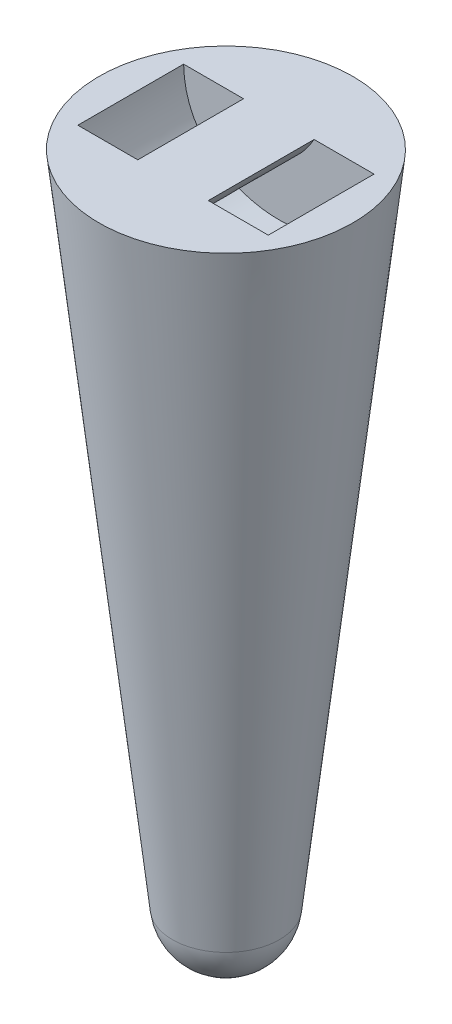
from build123d import *

# Parameters (mm, degrees)
ENL_V_MAT_EXTRU_1_DEPTH      = 7.5
ENL_V_MAT_EXTRU_1_DEPTH_BACK = 7.5
BOSS_EXTRU_1_REACH           = 27.5
ECHELLE1_SCALE               = 2


with BuildPart() as part:
    # Esquisse1 → R_volution1 (revolve)
    with BuildSketch(Plane.XY):
        with BuildLine():
            Line((0, 0), (0, 100))
            Line((0, 100), (-18, 100))
            Line((-18, 100), (-7.593007693, 6.792401612))
            ThreePointArc((-7.593007693, 6.792401612), (-5.093880777, 1.945904787), (0, 0))
        make_face()
    revolve(axis=Axis((0, 0, 0), (0, 1, 0)))

    # Esquisse2 → Enl_v. mat.-Extru.1 (cut, two sides)
    with BuildSketch(Plane.XY) as enl_v_mat_extru_1_sk:
        with BuildLine():
            Line((-13.5, 100), (13.5, 100))
            add(Edge.make_bspline(
                [(-13.5, 100), (-13.291113541, 83.520875666), (13.291113541, 83.520875666), (13.5, 100)],
                knots=[0, 0, 0, 0, 1, 1, 1, 1], degree=3))
        make_face()
    extrude(amount=ENL_V_MAT_EXTRU_1_DEPTH, mode=Mode.SUBTRACT)
    extrude(enl_v_mat_extru_1_sk.sketch, amount=-ENL_V_MAT_EXTRU_1_DEPTH_BACK, mode=Mode.SUBTRACT)

    # Esquisse3 → Boss.-Extru.1 (add, up to next)
    with BuildSketch(Plane.XY.offset(-7.5), mode=Mode.PRIVATE) as boss_extru_1_sk1:
        with BuildLine():
            Line((-5, 100), (5, 100))
            add(Edge.make_bspline(
                [(-5, 100), (0, 91.498247822), (5, 100)],
                knots=[0, 0, 0, 1, 1, 1], degree=2))
        make_face()
    boss_extru_1_tool1 = extrude(boss_extru_1_sk1.sketch, amount=BOSS_EXTRU_1_REACH, mode=Mode.PRIVATE) - part.part
    add(boss_extru_1_tool1.solids().sort_by_distance((0, 98.29965, -7.5))[0])


with BuildPart() as part_1:
    # Echelle1: scaled about (-4e-09, 62.219241992, 3e-09)
    add(part.part.scale(ECHELLE1_SCALE).moved(Location((4e-09, -62.219241992, -3e-09))))


solid = part_1.part
